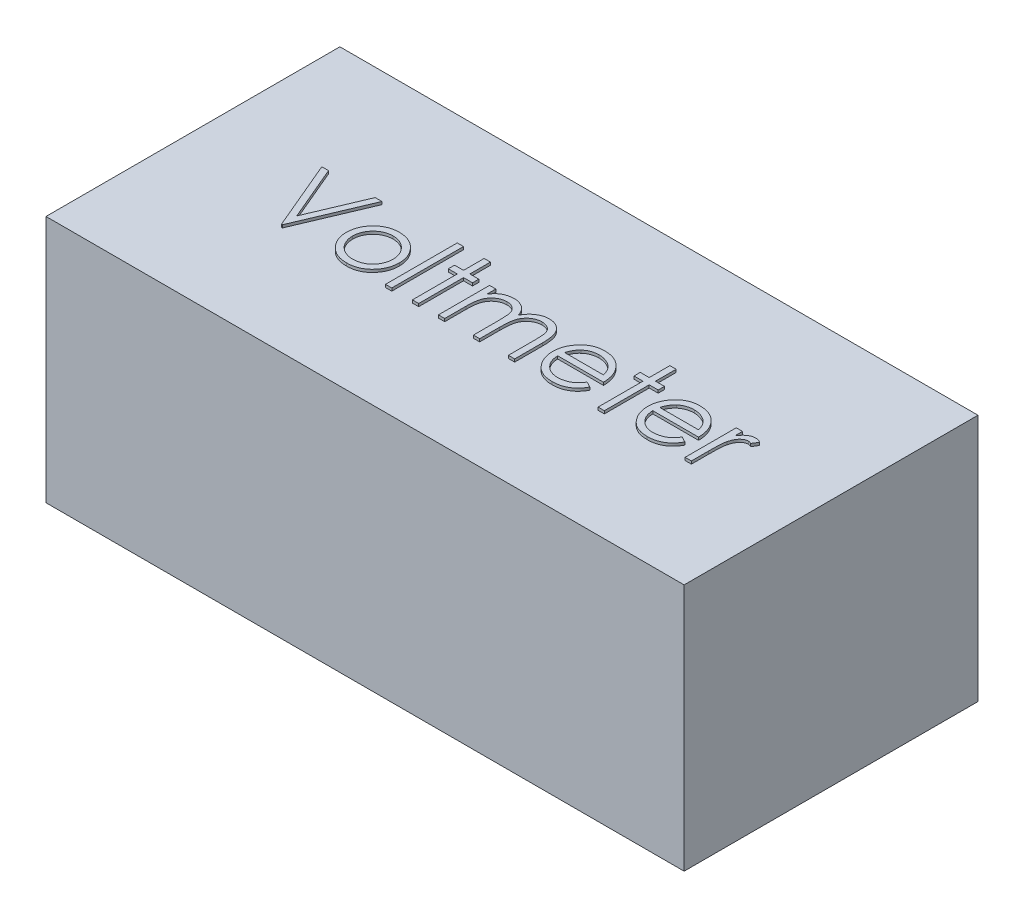
from build123d import *

# Parameters (mm, degrees)
SKETCH1_W           = 22.8
SKETCH1_H           = 10.5
BOSS_EXTRUDE1_DEPTH = 8.86
SKETCH2_W           = 0.224358975
SKETCH2_H           = 2.564102564
BOSS_EXTRUDE2_DEPTH = 0.1


with BuildPart() as part:
    # Sketch1 → Boss-Extrude1 (new body)
    with BuildSketch(Plane(origin=(0, 0, 0), x_dir=(1, 0, 0), z_dir=(0, 1, 0))):
        with Locations((-2.668502582, 3.147934596)):
            Rectangle(SKETCH1_W, SKETCH1_H)
    extrude(amount=BOSS_EXTRUDE1_DEPTH)

    # Sketch2 → Boss-Extrude2 (add)
    with BuildSketch(Plane(origin=(0, 8.86, 0), x_dir=(1, 0, 0), z_dir=(0, 1, 0))):
        Polygon((-10.579076241, 4.262906353), (-10.338691626, 4.262906353), (-9.505358293, 2.292754109), (-8.672024959, 4.262906353), (-8.431640344, 4.262906353), (-9.489332652, 1.762906353), (-9.521383934, 1.762906353), align=None)
        with BuildLine():
            add(Edge.make_bspline(
                [(-7.1646131, 3.621880712), (-7.13033362, 3.621150789), (-7.063119936, 3.61971959), (-6.964685731, 3.604423186), (-6.87072492, 3.581032212), (-6.78087764, 3.548695382), (-6.696294572, 3.505351131), (-6.615743683, 3.453630209), (-6.53944582, 3.392356928), (-6.493715084, 3.344958308), (-6.470502523, 3.320899141)],
                knots=[0, 0, 0, 0, 0.000102763, 0.000201493, 0.000298056, 0.000392956, 0.000487246, 0.000582542, 0.000679761, 0.000779978, 0.000779978, 0.000779978, 0.000779978], degree=3))
            add(Edge.make_bspline(
                [(-6.470502523, 3.320899141), (-6.450515413, 3.297889151), (-6.410927999, 3.252314478), (-6.360166771, 3.178417612), (-6.316437085, 3.101888969), (-6.281392113, 3.021712307), (-6.253759953, 2.938587542), (-6.234141599, 2.852228962), (-6.22247236, 2.762827286), (-6.220898812, 2.702110258), (-6.220101882, 2.671359878)],
                knots=[0, 0, 0, 0, 9.1373e-05, 0.000180977, 0.000268438, 0.000355441, 0.000443018, 0.000530854, 0.000620738, 0.000712972, 0.000712972, 0.000712972, 0.000712972], degree=3))
            add(Edge.make_bspline(
                [(-6.220101882, 2.671359878), (-6.220802838, 2.640431266), (-6.222187958, 2.579314885), (-6.235290541, 2.489301052), (-6.255669888, 2.402019036), (-6.284835487, 2.317834255), (-6.322234136, 2.236489378), (-6.367870341, 2.1583397), (-6.422064354, 2.083231033), (-6.48349578, 2.011801149), (-6.551389977, 1.945968138), (-6.625044369, 1.888590803), (-6.703011536, 1.839432571), (-6.786328217, 1.799835131), (-6.874233565, 1.768613917), (-6.966917185, 1.746685334), (-7.064235092, 1.733426988), (-7.130683107, 1.731724436), (-7.1646131, 1.730855071)],
                knots=[0, 0, 0, 0, 9.2735e-05, 0.000183248, 0.000272287, 0.000361294, 0.000450032, 0.000540478, 0.000632345, 0.000727513, 0.000822787, 0.000915553, 0.001007125, 0.00109874, 0.001191718, 0.001286463, 0.001383991, 0.001485753, 0.001485753, 0.001485753, 0.001485753], degree=3))
            add(Edge.make_bspline(
                [(-7.1646131, 1.730855071), (-7.198709328, 1.731727354), (-7.265488514, 1.733435764), (-7.36314993, 1.746633823), (-7.455999657, 1.768603811), (-7.544020085, 1.799937734), (-7.627694976, 1.839433837), (-7.706113902, 1.888442186), (-7.779828127, 1.945985154), (-7.847736688, 2.011796538), (-7.909164263, 2.083232221), (-7.963359269, 2.158339391), (-8.008995216, 2.236489458), (-8.046393933, 2.317834233), (-8.075559514, 2.402019042), (-8.095938866, 2.489301051), (-8.109041448, 2.579314885), (-8.110426568, 2.640431266), (-8.111127523, 2.671359878)],
                knots=[0, 0, 0, 0, 0.000102263, 0.000200287, 0.000295032, 0.00038801, 0.000480077, 0.000572074, 0.00066484, 0.000760114, 0.000855282, 0.000947149, 0.001037595, 0.001126333, 0.00121534, 0.001304379, 0.001394892, 0.001487627, 0.001487627, 0.001487627, 0.001487627], degree=3))
            add(Edge.make_bspline(
                [(-8.111127523, 2.671359878), (-8.110325159, 2.701943125), (-8.108736615, 2.762492699), (-8.097079108, 2.851726313), (-8.077537282, 2.937938734), (-8.049871999, 3.020742645), (-8.014504006, 3.100567957), (-7.9713888, 3.177285693), (-7.920109777, 3.250848408), (-7.880679811, 3.296364179), (-7.860726882, 3.319396737)],
                knots=[0, 0, 0, 0, 9.1734e-05, 0.000181618, 0.000269454, 0.000356556, 0.0004431, 0.000530998, 0.000620191, 0.000711564, 0.000711564, 0.000711564, 0.000711564], degree=3))
            add(Edge.make_bspline(
                [(-7.860726882, 3.319396737), (-7.837549317, 3.343664551), (-7.791966557, 3.391391477), (-7.715288895, 3.452486137), (-7.634936165, 3.505283333), (-7.549418361, 3.547766344), (-7.459644891, 3.581222428), (-7.365202575, 3.60448351), (-7.26643435, 3.619664478), (-7.198891763, 3.621134605), (-7.1646131, 3.621880712)],
                knots=[0, 0, 0, 0, 0.00010057, 0.000197789, 0.000293357, 0.000388542, 0.000483615, 0.000580177, 0.000679898, 0.000782662, 0.000782662, 0.000782662, 0.000782662], degree=3))
        make_face()
        with BuildLine():
            add(Edge.make_bspline(
                [(-7.165614703, 3.397521737), (-7.189855854, 3.396832743), (-7.237712374, 3.395472541), (-7.308154935, 3.385126895), (-7.37596933, 3.368735821), (-7.441284219, 3.345447209), (-7.503879342, 3.315376567), (-7.56381463, 3.278442024), (-7.621266372, 3.23513277), (-7.675110703, 3.185516576), (-7.724526641, 3.131317294), (-7.767725195, 3.073568466), (-7.804457414, 3.01320679), (-7.835057528, 2.950169496), (-7.857848376, 2.883817772), (-7.874400535, 2.814903036), (-7.884736421, 2.743284881), (-7.886083835, 2.694598439), (-7.886768549, 2.669857475)],
                knots=[0, 0, 0, 0, 7.2701e-05, 0.000143525, 0.000213124, 0.000281711, 0.00035115, 0.000421065, 0.000492579, 0.000566659, 0.000640401, 0.000712316, 0.000782659, 0.000852097, 0.000922102, 0.000992674, 0.00106449, 0.001138691, 0.001138691, 0.001138691, 0.001138691], degree=3))
            add(Edge.make_bspline(
                [(-7.886768549, 2.669857475), (-7.885620818, 2.637891741), (-7.883342786, 2.574445737), (-7.864817617, 2.481009221), (-7.833827417, 2.391307898), (-7.79197936, 2.305867622), (-7.739546347, 2.226815995), (-7.677769871, 2.156336363), (-7.607312942, 2.095489355), (-7.529015442, 2.045003037), (-7.444476643, 2.004888926), (-7.355007842, 1.976461086), (-7.261693061, 1.957981305), (-7.19792111, 1.956144538), (-7.165614703, 1.955214045)],
                knots=[0, 0, 0, 0, 9.5842e-05, 0.000190228, 0.00028446, 0.000379871, 0.000474877, 0.000568205, 0.000660168, 0.000753238, 0.000846877, 0.000940002, 0.001034294, 0.001131105, 0.001131105, 0.001131105, 0.001131105], degree=3))
            add(Edge.make_bspline(
                [(-7.165614703, 1.955214045), (-7.133310154, 1.956149959), (-7.069541871, 1.957997429), (-6.976356744, 1.976368014), (-6.887132479, 2.005013486), (-6.802681488, 2.044957922), (-6.724419628, 2.095681075), (-6.65345597, 2.155992773), (-6.592206962, 2.227002667), (-6.539825816, 2.30597233), (-6.497292428, 2.391175439), (-6.466447284, 2.481025776), (-6.44787758, 2.574441521), (-6.445605559, 2.637890328), (-6.444460857, 2.669857475)],
                knots=[0, 0, 0, 0, 9.6812e-05, 0.000191103, 0.000283751, 0.000377391, 0.00047046, 0.000562803, 0.000655801, 0.000750807, 0.000846441, 0.000940673, 0.001035059, 0.0011309, 0.0011309, 0.0011309, 0.0011309], degree=3))
            add(Edge.make_bspline(
                [(-6.444460857, 2.669857475), (-6.445145335, 2.694598587), (-6.446492285, 2.74328532), (-6.456831545, 2.814901358), (-6.473371216, 2.883823927), (-6.496208086, 2.950146787), (-6.526675238, 3.013370004), (-6.564115805, 3.073391238), (-6.607137966, 3.131517342), (-6.657150195, 3.185341371), (-6.710938322, 3.235152111), (-6.768413349, 3.278458818), (-6.828259763, 3.315214243), (-6.890673036, 3.345704415), (-6.955996299, 3.368523944), (-7.023715677, 3.385221538), (-7.093857684, 3.395428821), (-7.141542714, 3.396819637), (-7.165614703, 3.397521737)],
                knots=[0, 0, 0, 0, 7.4201e-05, 0.000146017, 0.000216589, 0.000286594, 0.000356032, 0.000426636, 0.000498551, 0.000572631, 0.000646711, 0.000718226, 0.000788141, 0.000857128, 0.000926188, 0.0009953, 0.001066124, 0.001138324, 0.001138324, 0.001138324, 0.001138324], degree=3))
        make_face(mode=Mode.SUBTRACT)
        with Locations((-5.691255728, 3.044957635)):
            Rectangle(SKETCH2_W, SKETCH2_H)
        Polygon((-4.841896754, 4.327008917), (-4.61753778, 4.327008917), (-4.61753778, 3.58982943), (-4.297024959, 3.58982943), (-4.297024959, 3.365470455), (-4.61753778, 3.365470455), (-4.61753778, 1.762906353), (-4.841896754, 1.762906353), (-4.841896754, 3.365470455), (-5.162409575, 3.365470455), (-5.162409575, 3.58982943), (-4.841896754, 3.58982943), align=None)
        with BuildLine():
            Line((-3.912409575, 3.58982943), (-3.6880506, 3.58982943))
            Line((-3.6880506, 3.58982943), (-3.6880506, 3.272321417))
            add(Edge.make_bspline(
                [(-3.6880506, 3.272321417), (-3.667847779, 3.300098275), (-3.629137236, 3.353321399), (-3.56566177, 3.423457316), (-3.502250261, 3.482977427), (-3.45658356, 3.514222335), (-3.434645152, 3.529232475)],
                knots=[0, 0, 0, 0, 0.000102966, 0.000197292, 0.000283431, 0.000363073, 0.000363073, 0.000363073, 0.000363073], degree=3))
            add(Edge.make_bspline(
                [(-3.434645152, 3.529232475), (-3.404741821, 3.543522021), (-3.345457607, 3.571851459), (-3.251586732, 3.600589716), (-3.155533397, 3.618250502), (-3.090670387, 3.620665769), (-3.058042587, 3.621880712)],
                knots=[0, 0, 0, 0, 9.9308e-05, 0.000196881, 0.000293544, 0.000391385, 0.000391385, 0.000391385, 0.000391385], degree=3))
            add(Edge.make_bspline(
                [(-3.058042587, 3.621880712), (-3.035976161, 3.621134075), (-2.992307891, 3.619656522), (-2.927604969, 3.610042212), (-2.864848818, 3.593423517), (-2.804410225, 3.570275428), (-2.747466883, 3.54224208), (-2.695260313, 3.509349432), (-2.648385879, 3.472422949), (-2.606867271, 3.42979514), (-2.569532253, 3.380268998), (-2.535190219, 3.32250882), (-2.503457925, 3.255217634), (-2.485871276, 3.20638439), (-2.476612299, 3.180674782)],
                knots=[0, 0, 0, 0, 6.6199e-05, 0.000131004, 0.000195748, 0.000260577, 0.000324855, 0.00038585, 0.00044537, 0.00050345, 0.000563848, 0.000631011, 0.000704712, 0.000786656, 0.000786656, 0.000786656, 0.000786656], degree=3))
            add(Edge.make_bspline(
                [(-2.476612299, 3.180674782), (-2.466818548, 3.198335082), (-2.447545821, 3.233088071), (-2.415184652, 3.282272544), (-2.381279083, 3.328277395), (-2.34554016, 3.371139127), (-2.308094026, 3.410646077), (-2.268764455, 3.446928864), (-2.227775325, 3.480143303), (-2.170780868, 3.518945559), (-2.096629005, 3.560160689), (-2.003137495, 3.595895292), (-1.905887372, 3.617978241), (-1.839874731, 3.620571293), (-1.806540184, 3.621880712)],
                knots=[0, 0, 0, 0, 6.0564e-05, 0.000119181, 0.000176474, 0.000231939, 0.000286492, 0.000339652, 0.000392367, 0.000444597, 0.000546357, 0.000646062, 0.000744001, 0.000843906, 0.000843906, 0.000843906, 0.000843906], degree=3))
            add(Edge.make_bspline(
                [(-1.806540184, 3.621880712), (-1.775910567, 3.620725554), (-1.715965434, 3.618464798), (-1.628695959, 3.600712317), (-1.547308955, 3.570228283), (-1.471968186, 3.528632829), (-1.403996891, 3.476361984), (-1.344913813, 3.414169957), (-1.295077839, 3.342496654), (-1.262521668, 3.275073805), (-1.240439336, 3.215548568), (-1.226824169, 3.164829788), (-1.214795815, 3.10900725), (-1.204809212, 3.048014206), (-1.197510246, 2.981635201), (-1.192102592, 2.909978861), (-1.188442539, 2.832989495), (-1.188183916, 2.779871281), (-1.1880506, 2.752489686)],
                knots=[0, 0, 0, 0, 9.1843e-05, 0.000179747, 0.000265793, 0.000351646, 0.00043699, 0.000522005, 0.000607999, 0.000697811, 0.000745818, 0.000798306, 0.00085518, 0.000917093, 0.000983624, 0.00105545, 0.001132653, 0.001214791, 0.001214791, 0.001214791, 0.001214791], degree=3))
            Line((-1.1880506, 2.752489686), (-1.1880506, 1.762906353))
            Line((-1.1880506, 1.762906353), (-1.412409575, 1.762906353))
            Line((-1.412409575, 1.762906353), (-1.412409575, 2.753491289))
            add(Edge.make_bspline(
                [(-1.412409575, 2.753491289), (-1.412465205, 2.776863127), (-1.412572119, 2.821780246), (-1.414496142, 2.886246283), (-1.418121366, 2.945009395), (-1.422360394, 2.997989458), (-1.428248829, 3.045310021), (-1.435853066, 3.086876035), (-1.443908551, 3.123014471), (-1.457291402, 3.163075934), (-1.478682753, 3.207268941), (-1.511266668, 3.254928638), (-1.552316744, 3.296414924), (-1.599716855, 3.332428008), (-1.65368003, 3.36170918), (-1.713154832, 3.382620615), (-1.777772012, 3.395565529), (-1.822502575, 3.39685554), (-1.845602684, 3.397521737)],
                knots=[0, 0, 0, 0, 7.0114e-05, 0.000134748, 0.000193447, 0.000246723, 0.00029418, 0.00033642, 0.000373469, 0.000405143, 0.000462933, 0.000520167, 0.000577538, 0.000637235, 0.000698186, 0.000760913, 0.000825735, 0.000894962, 0.000894962, 0.000894962, 0.000894962], degree=3))
            add(Edge.make_bspline(
                [(-1.845602684, 3.397521737), (-1.873938365, 3.396510196), (-1.929940445, 3.394511007), (-2.011687221, 3.374101098), (-2.090237947, 3.34332949), (-2.163248756, 3.298734878), (-2.230411464, 3.245300332), (-2.288196876, 3.181764907), (-2.335934152, 3.109886387), (-2.36825842, 3.043353028), (-2.38867935, 2.98358914), (-2.402162861, 2.931376731), (-2.412650998, 2.872032754), (-2.42248709, 2.805955975), (-2.428906896, 2.732691561), (-2.434741447, 2.652578417), (-2.437470635, 2.565375589), (-2.437852391, 2.504927954), (-2.4380506, 2.473543372)],
                knots=[0, 0, 0, 0, 8.4849e-05, 0.000167693, 0.000251297, 0.000337098, 0.000423288, 0.000508012, 0.000593573, 0.000681378, 0.000729048, 0.000782858, 0.000842971, 0.000909758, 0.000983211, 0.001063528, 0.001150719, 0.001244875, 0.001244875, 0.001244875, 0.001244875], degree=3))
            Line((-2.4380506, 2.473543372), (-2.4380506, 1.762906353))
            Line((-2.4380506, 1.762906353), (-2.662409575, 1.762906353))
            Line((-2.662409575, 1.762906353), (-2.662409575, 2.691892731))
            add(Edge.make_bspline(
                [(-2.662409575, 2.691892731), (-2.662466311, 2.718102244), (-2.662575466, 2.768526714), (-2.664487121, 2.840836482), (-2.668120423, 2.906608682), (-2.672320814, 2.96576687), (-2.678363799, 3.018203534), (-2.685227915, 3.064199789), (-2.693334065, 3.103640326), (-2.706755411, 3.146899887), (-2.727265746, 3.194557689), (-2.760257361, 3.245372704), (-2.801405633, 3.289849916), (-2.849670544, 3.327820451), (-2.903960317, 3.359207223), (-2.963948461, 3.381821332), (-3.029094827, 3.394981539), (-3.074007474, 3.396659036), (-3.097105087, 3.397521737)],
                knots=[0, 0, 0, 0, 7.8627e-05, 0.000151271, 0.00021697, 0.000276236, 0.000329162, 0.000375271, 0.00041574, 0.000449799, 0.000511021, 0.000570751, 0.000630649, 0.000691968, 0.000754333, 0.000818047, 0.000883459, 0.000952716, 0.000952716, 0.000952716, 0.000952716], degree=3))
            add(Edge.make_bspline(
                [(-3.097105087, 3.397521737), (-3.124259524, 3.396428552), (-3.178377352, 3.394249871), (-3.257878759, 3.374639676), (-3.334654248, 3.343922479), (-3.407479032, 3.301308323), (-3.474389138, 3.248523267), (-3.532966472, 3.186441198), (-3.582211133, 3.115834746), (-3.614876715, 3.050002948), (-3.635947054, 2.991736323), (-3.649943722, 2.942199932), (-3.661972026, 2.887199755), (-3.670910613, 2.826566104), (-3.679539481, 2.760693894), (-3.683703987, 2.689254973), (-3.687755103, 2.612310624), (-3.687949685, 2.559187378), (-3.6880506, 2.531636321)],
                knots=[0, 0, 0, 0, 8.1352e-05, 0.000162132, 0.000244155, 0.000328761, 0.000414326, 0.000498997, 0.000583882, 0.000671677, 0.000718571, 0.000769613, 0.000825997, 0.000887337, 0.000953429, 0.001025219, 0.001101921, 0.00118456, 0.00118456, 0.00118456, 0.00118456], degree=3))
            Line((-3.6880506, 2.531636321), (-3.6880506, 1.762906353))
            Line((-3.6880506, 1.762906353), (-3.912409575, 1.762906353))
            Line((-3.912409575, 1.762906353), (-3.912409575, 3.58982943))
        make_face()
        with BuildLine():
            Line((0.824168951, 2.33982943), (1.023487861, 2.235161962))
            add(Edge.make_bspline(
                [(1.023487861, 2.235161962), (1.007604579, 2.206988154), (0.976702002, 2.15217308), (0.92355861, 2.076864608), (0.867849987, 2.00911624), (0.807061438, 1.950737915), (0.743011668, 1.899844069), (0.675345486, 1.855317051), (0.603710616, 1.817375251), (0.52810367, 1.78540916), (0.447889704, 1.76083095), (0.362874336, 1.743470792), (0.272894696, 1.732739886), (0.211218853, 1.731493357), (0.179637701, 1.730855071)],
                knots=[0, 0, 0, 0, 9.6971e-05, 0.000188667, 0.000276128, 0.000359712, 0.000440975, 0.000521259, 0.00060236, 0.000683837, 0.000767159, 0.000853591, 0.000943849, 0.001038565, 0.001038565, 0.001038565, 0.001038565], degree=3))
            add(Edge.make_bspline(
                [(0.179637701, 1.730855071), (0.144536289, 1.731674482), (0.076063602, 1.733272915), (-0.023607646, 1.747053247), (-0.117450088, 1.769533503), (-0.205458448, 1.800937461), (-0.287417199, 1.841956978), (-0.363489239, 1.891928037), (-0.434074614, 1.950593933), (-0.496949049, 2.018462821), (-0.553551823, 2.091092791), (-0.603498837, 2.166775565), (-0.645254145, 2.245320726), (-0.679220295, 2.326228243), (-0.706652341, 2.408988167), (-0.725771416, 2.494353501), (-0.736792664, 2.582093204), (-0.738481554, 2.641448444), (-0.739332652, 2.671359878)],
                knots=[0, 0, 0, 0, 0.000105265, 0.000205341, 0.000301178, 0.000394324, 0.00048503, 0.000575455, 0.000666827, 0.00075965, 0.000852416, 0.000942841, 0.001031335, 0.001118861, 0.001205806, 0.001292554, 0.001380884, 0.001470617, 0.001470617, 0.001470617, 0.001470617], degree=3))
            add(Edge.make_bspline(
                [(-0.739332652, 2.671359878), (-0.738576122, 2.699427614), (-0.73707678, 2.755054161), (-0.727626218, 2.837386692), (-0.710877437, 2.917407016), (-0.687894349, 2.995181621), (-0.658214887, 3.070580288), (-0.621906159, 3.143648905), (-0.578911604, 3.214309719), (-0.545716837, 3.258883386), (-0.528996113, 3.28133584)],
                knots=[0, 0, 0, 0, 8.4208e-05, 0.000166888, 0.000248213, 0.000329183, 0.000409905, 0.000490981, 0.000573692, 0.000657642, 0.000657642, 0.000657642, 0.000657642], degree=3))
            add(Edge.make_bspline(
                [(-0.528996113, 3.28133584), (-0.506347768, 3.308385033), (-0.461768521, 3.361626569), (-0.386371124, 3.431582516), (-0.304728127, 3.490185212), (-0.217862679, 3.538761738), (-0.124765198, 3.575671486), (-0.026687133, 3.603176902), (0.077488286, 3.618589767), (0.148706301, 3.620766791), (0.185146515, 3.621880712)],
                knots=[0, 0, 0, 0, 0.000105765, 0.00020818, 0.000307557, 0.000406641, 0.000505962, 0.000607293, 0.00071162, 0.000820933, 0.000820933, 0.000820933, 0.000820933], degree=3))
            add(Edge.make_bspline(
                [(0.185146515, 3.621880712), (0.22260909, 3.620913534), (0.296102123, 3.619016152), (0.403267924, 3.601425913), (0.504668436, 3.573531232), (0.600263082, 3.534135667), (0.690061554, 3.483307416), (0.77348016, 3.420348957), (0.851945527, 3.347193181), (0.897594511, 3.290933746), (0.920823598, 3.262305391)],
                knots=[0, 0, 0, 0, 0.000112315, 0.000220336, 0.000324831, 0.000427226, 0.000529719, 0.000633485, 0.000740123, 0.000850609, 0.000850609, 0.000850609, 0.000850609], degree=3))
            add(Edge.make_bspline(
                [(0.920823598, 3.262305391), (0.936628554, 3.240731404), (0.968133264, 3.197727034), (1.007595478, 3.127604779), (1.04185076, 3.054240069), (1.069231447, 2.976446999), (1.091402519, 2.895147299), (1.107443104, 2.809759767), (1.116849974, 2.720309831), (1.118699044, 2.659362291), (1.119641707, 2.628290968)],
                knots=[0, 0, 0, 0, 8.0167e-05, 0.000159801, 0.000240914, 0.000322808, 0.000406877, 0.000493509, 0.000583158, 0.000676393, 0.000676393, 0.000676393, 0.000676393], degree=3))
            Line((1.119641707, 2.628290968), (-0.514973677, 2.628290968))
            add(Edge.make_bspline(
                [(-0.514973677, 2.628290968), (-0.513873958, 2.604219208), (-0.511711405, 2.556883062), (-0.50162916, 2.487618217), (-0.485737179, 2.421637259), (-0.463402134, 2.359435086), (-0.436354388, 2.30019928), (-0.403221733, 2.244369254), (-0.36369348, 2.192199304), (-0.319603695, 2.143222777), (-0.270527198, 2.099607948), (-0.218896664, 2.060570965), (-0.163972689, 2.027852681), (-0.106188344, 2.001295617), (-0.045637069, 1.980505391), (0.017700213, 1.966314091), (0.083698868, 1.956809015), (0.128688678, 1.955752111), (0.151592829, 1.955214045)],
                knots=[0, 0, 0, 0, 7.2256e-05, 0.000142089, 0.000209623, 0.000275516, 0.000340049, 0.000404722, 0.000469826, 0.000536124, 0.000602085, 0.000666488, 0.000730044, 0.000793459, 0.000856966, 0.000921716, 0.000987938, 0.001056613, 0.001056613, 0.001056613, 0.001056613], degree=3))
            add(Edge.make_bspline(
                [(0.151592829, 1.955214045), (0.173986506, 1.955648371), (0.218419857, 1.956510158), (0.284591898, 1.964890094), (0.34969156, 1.978440291), (0.413449405, 1.996933141), (0.474571438, 2.019488035), (0.531175402, 2.046704362), (0.583232699, 2.076811324), (0.631887675, 2.111246806), (0.679081242, 2.153395511), (0.725897304, 2.205992455), (0.776094913, 2.268197832), (0.807516051, 2.315016165), (0.824168951, 2.33982943)],
                knots=[0, 0, 0, 0, 6.7154e-05, 0.000133247, 0.00019974, 0.000266467, 0.000332232, 0.000394953, 0.000454649, 0.000512458, 0.00057347, 0.000644012, 0.000723475, 0.000813079, 0.000813079, 0.000813079, 0.000813079], degree=3))
        make_face()
        with BuildLine():
            add(Edge.make_bspline(
                [(0.895282733, 2.852649942), (0.887070858, 2.882409138), (0.871265643, 2.93968601), (0.838239668, 3.019000932), (0.801045711, 3.089492289), (0.757030188, 3.150620599), (0.70715967, 3.204908822), (0.649555968, 3.252350669), (0.584958901, 3.294791705), (0.513702372, 3.330614919), (0.438243954, 3.361107675), (0.359239532, 3.381554187), (0.278626826, 3.395561003), (0.224102336, 3.396865366), (0.196664945, 3.397521737)],
                knots=[0, 0, 0, 0, 9.253e-05, 0.000178091, 0.000257189, 0.000331125, 0.000403421, 0.000477737, 0.000554411, 0.000634817, 0.000716655, 0.000798045, 0.000879224, 0.000961454, 0.000961454, 0.000961454, 0.000961454], degree=3))
            add(Edge.make_bspline(
                [(0.196664945, 3.397521737), (0.174272489, 3.397084829), (0.130007311, 3.396221153), (0.064792262, 3.388028204), (0.002163906, 3.374485457), (-0.058339871, 3.35593906), (-0.115926206, 3.33121863), (-0.171779612, 3.302230611), (-0.224479895, 3.266843765), (-0.257437963, 3.239873154), (-0.27408826, 3.226247699)],
                knots=[0, 0, 0, 0, 6.7154e-05, 0.000132749, 0.000196793, 0.000259203, 0.000322266, 0.000384543, 0.000447741, 0.000512267, 0.000512267, 0.000512267, 0.000512267], degree=3))
            add(Edge.make_bspline(
                [(-0.27408826, 3.226247699), (-0.286012033, 3.215466045), (-0.310142843, 3.193646605), (-0.342386073, 3.156054314), (-0.373257839, 3.115517484), (-0.401353306, 3.070485252), (-0.42712301, 3.02147041), (-0.45123728, 2.968886385), (-0.47294186, 2.912334149), (-0.485153367, 2.872925264), (-0.491436017, 2.852649942)],
                knots=[0, 0, 0, 0, 4.8181e-05, 9.7507e-05, 0.000148288, 0.000200949, 0.000256508, 0.000314326, 0.000374408, 0.000438075, 0.000438075, 0.000438075, 0.000438075], degree=3))
            Line((-0.491436017, 2.852649942), (0.895282733, 2.852649942))
        make_face(mode=Mode.SUBTRACT)
        Polygon((1.792718631, 4.327008917), (2.017077605, 4.327008917), (2.017077605, 3.58982943), (2.337590425, 3.58982943), (2.337590425, 3.365470455), (2.017077605, 3.365470455), (2.017077605, 1.762906353), (1.792718631, 1.762906353), (1.792718631, 3.365470455), (1.47220581, 3.365470455), (1.47220581, 3.58982943), (1.792718631, 3.58982943), align=None)
        with BuildLine():
            Line((4.221604848, 2.33982943), (4.420923759, 2.235161962))
            add(Edge.make_bspline(
                [(4.420923759, 2.235161962), (4.405040476, 2.206988154), (4.374137899, 2.15217308), (4.320994508, 2.076864608), (4.265285884, 2.00911624), (4.204497336, 1.950737915), (4.140447565, 1.899844069), (4.072781383, 1.855317051), (4.001146513, 1.817375251), (3.925539567, 1.78540916), (3.845325602, 1.76083095), (3.760310233, 1.743470792), (3.670330593, 1.732739886), (3.608654751, 1.731493357), (3.577073598, 1.730855071)],
                knots=[0, 0, 0, 0, 9.6971e-05, 0.000188667, 0.000276128, 0.000359712, 0.000440975, 0.000521259, 0.00060236, 0.000683837, 0.000767159, 0.000853591, 0.000943849, 0.001038565, 0.001038565, 0.001038565, 0.001038565], degree=3))
            add(Edge.make_bspline(
                [(3.577073598, 1.730855071), (3.541972186, 1.731674482), (3.473499499, 1.733272915), (3.373828251, 1.747053247), (3.279985809, 1.769533503), (3.19197745, 1.800937461), (3.110018698, 1.841956978), (3.033946659, 1.891928037), (2.963361283, 1.950593933), (2.900486848, 2.018462821), (2.843884075, 2.091092791), (2.79393706, 2.166775565), (2.752181753, 2.245320726), (2.718215602, 2.326228243), (2.690783556, 2.408988167), (2.671664482, 2.494353501), (2.660643233, 2.582093204), (2.658954344, 2.641448444), (2.658103246, 2.671359878)],
                knots=[0, 0, 0, 0, 0.000105265, 0.000205341, 0.000301178, 0.000394324, 0.00048503, 0.000575455, 0.000666827, 0.00075965, 0.000852416, 0.000942841, 0.001031335, 0.001118861, 0.001205806, 0.001292554, 0.001380884, 0.001470617, 0.001470617, 0.001470617, 0.001470617], degree=3))
            add(Edge.make_bspline(
                [(2.658103246, 2.671359878), (2.658859775, 2.699427614), (2.660359117, 2.755054161), (2.669809679, 2.837386692), (2.68655846, 2.917407016), (2.709541549, 2.995181621), (2.73922101, 3.070580288), (2.775529738, 3.143648905), (2.818524294, 3.214309719), (2.851719061, 3.258883386), (2.868439784, 3.28133584)],
                knots=[0, 0, 0, 0, 8.4208e-05, 0.000166888, 0.000248213, 0.000329183, 0.000409905, 0.000490981, 0.000573692, 0.000657642, 0.000657642, 0.000657642, 0.000657642], degree=3))
            add(Edge.make_bspline(
                [(2.868439784, 3.28133584), (2.891088129, 3.308385033), (2.935667377, 3.361626569), (3.011064773, 3.431582516), (3.092707771, 3.490185212), (3.179573218, 3.538761738), (3.2726707, 3.575671486), (3.370748765, 3.603176902), (3.474924183, 3.618589767), (3.546142198, 3.620766791), (3.582582413, 3.621880712)],
                knots=[0, 0, 0, 0, 0.000105765, 0.00020818, 0.000307557, 0.000406641, 0.000505962, 0.000607293, 0.00071162, 0.000820933, 0.000820933, 0.000820933, 0.000820933], degree=3))
            add(Edge.make_bspline(
                [(3.582582413, 3.621880712), (3.620044988, 3.620913534), (3.693538021, 3.619016152), (3.800703821, 3.601425913), (3.902104333, 3.573531232), (3.997698979, 3.534135667), (4.087497451, 3.483307416), (4.170916058, 3.420348957), (4.249381424, 3.347193181), (4.295030409, 3.290933746), (4.318259496, 3.262305391)],
                knots=[0, 0, 0, 0, 0.000112315, 0.000220336, 0.000324831, 0.000427226, 0.000529719, 0.000633485, 0.000740123, 0.000850609, 0.000850609, 0.000850609, 0.000850609], degree=3))
            add(Edge.make_bspline(
                [(4.318259496, 3.262305391), (4.334064452, 3.240731404), (4.365569161, 3.197727034), (4.405031376, 3.127604779), (4.439286658, 3.054240069), (4.466667344, 2.976446999), (4.488838416, 2.895147299), (4.504879001, 2.809759767), (4.514285872, 2.720309831), (4.516134941, 2.659362291), (4.517077605, 2.628290968)],
                knots=[0, 0, 0, 0, 8.0167e-05, 0.000159801, 0.000240914, 0.000322808, 0.000406877, 0.000493509, 0.000583158, 0.000676393, 0.000676393, 0.000676393, 0.000676393], degree=3))
            Line((4.517077605, 2.628290968), (2.88246222, 2.628290968))
            add(Edge.make_bspline(
                [(2.88246222, 2.628290968), (2.883561939, 2.604219208), (2.885724492, 2.556883062), (2.895806737, 2.487618217), (2.911698718, 2.421637259), (2.934033763, 2.359435086), (2.96108151, 2.30019928), (2.994214165, 2.244369254), (3.033742417, 2.192199304), (3.077832203, 2.143222777), (3.126908699, 2.099607948), (3.178539233, 2.060570965), (3.233463208, 2.027852681), (3.291247553, 2.001295617), (3.351798829, 1.980505391), (3.415136111, 1.966314091), (3.481134765, 1.956809015), (3.526124575, 1.955752111), (3.549028727, 1.955214045)],
                knots=[0, 0, 0, 0, 7.2256e-05, 0.000142089, 0.000209623, 0.000275516, 0.000340049, 0.000404722, 0.000469826, 0.000536124, 0.000602085, 0.000666488, 0.000730044, 0.000793459, 0.000856966, 0.000921716, 0.000987938, 0.001056613, 0.001056613, 0.001056613, 0.001056613], degree=3))
            add(Edge.make_bspline(
                [(3.549028727, 1.955214045), (3.571422404, 1.955648371), (3.615855754, 1.956510158), (3.682027795, 1.964890094), (3.747127458, 1.978440291), (3.810885303, 1.996933141), (3.872007336, 2.019488035), (3.9286113, 2.046704362), (3.980668597, 2.076811324), (4.029323573, 2.111246806), (4.07651714, 2.153395511), (4.123333201, 2.205992455), (4.173530811, 2.268197832), (4.204951949, 2.315016165), (4.221604848, 2.33982943)],
                knots=[0, 0, 0, 0, 6.7154e-05, 0.000133247, 0.00019974, 0.000266467, 0.000332232, 0.000394953, 0.000454649, 0.000512458, 0.00057347, 0.000644012, 0.000723475, 0.000813079, 0.000813079, 0.000813079, 0.000813079], degree=3))
        make_face()
        with BuildLine():
            add(Edge.make_bspline(
                [(4.292718631, 2.852649942), (4.284506756, 2.882409138), (4.268701541, 2.93968601), (4.235675566, 3.019000932), (4.198481608, 3.089492289), (4.154466086, 3.150620599), (4.104595568, 3.204908822), (4.046991866, 3.252350669), (3.982394799, 3.294791705), (3.91113827, 3.330614919), (3.835679852, 3.361107675), (3.756675429, 3.381554187), (3.676062723, 3.395561003), (3.621538233, 3.396865366), (3.594100842, 3.397521737)],
                knots=[0, 0, 0, 0, 9.253e-05, 0.000178091, 0.000257189, 0.000331125, 0.000403421, 0.000477737, 0.000554411, 0.000634817, 0.000716655, 0.000798045, 0.000879224, 0.000961454, 0.000961454, 0.000961454, 0.000961454], degree=3))
            add(Edge.make_bspline(
                [(3.594100842, 3.397521737), (3.571708386, 3.397084829), (3.527443208, 3.396221153), (3.462228159, 3.388028204), (3.399599803, 3.374485457), (3.339096026, 3.35593906), (3.281509692, 3.33121863), (3.225656286, 3.302230611), (3.172956003, 3.266843765), (3.139997934, 3.239873154), (3.123347637, 3.226247699)],
                knots=[0, 0, 0, 0, 6.7154e-05, 0.000132749, 0.000196793, 0.000259203, 0.000322266, 0.000384543, 0.000447741, 0.000512267, 0.000512267, 0.000512267, 0.000512267], degree=3))
            add(Edge.make_bspline(
                [(3.123347637, 3.226247699), (3.111423864, 3.215466045), (3.087293054, 3.193646605), (3.055049824, 3.156054314), (3.024178058, 3.115517484), (2.996082592, 3.070485252), (2.970312887, 3.02147041), (2.946198618, 2.968886385), (2.924494038, 2.912334149), (2.912282531, 2.872925264), (2.905999881, 2.852649942)],
                knots=[0, 0, 0, 0, 4.8181e-05, 9.7507e-05, 0.000148288, 0.000200949, 0.000256508, 0.000314326, 0.000374408, 0.000438075, 0.000438075, 0.000438075, 0.000438075], degree=3))
            Line((2.905999881, 2.852649942), (4.292718631, 2.852649942))
        make_face(mode=Mode.SUBTRACT)
        with BuildLine():
            Line((4.90169299, 3.58982943), (5.126051964, 3.58982943))
            Line((5.126051964, 3.58982943), (5.126051964, 3.320899141))
            add(Edge.make_bspline(
                [(5.126051964, 3.320899141), (5.142615363, 3.345939019), (5.174292735, 3.393827589), (5.226944827, 3.457162804), (5.280875778, 3.509602123), (5.336343769, 3.551390351), (5.393756698, 3.582685436), (5.45185452, 3.605609032), (5.511551285, 3.619164258), (5.551666945, 3.620974014), (5.571765105, 3.621880712)],
                knots=[0, 0, 0, 0, 9.0016e-05, 0.000172155, 0.000246534, 0.000315244, 0.000379793, 0.000442104, 0.000502127, 0.000562392, 0.000562392, 0.000562392, 0.000562392], degree=3))
            add(Edge.make_bspline(
                [(5.571765105, 3.621880712), (5.587355338, 3.621030336), (5.619433256, 3.619280631), (5.667992249, 3.606987185), (5.718023286, 3.587360026), (5.750267848, 3.568902724), (5.767077605, 3.559280551)],
                knots=[0, 0, 0, 0, 4.6747e-05, 9.6184e-05, 0.000149472, 0.000207506, 0.000207506, 0.000207506, 0.000207506], degree=3))
            Line((5.767077605, 3.559280551), (5.64388049, 3.364969654))
            add(Edge.make_bspline(
                [(5.64388049, 3.364969654), (5.633088332, 3.36978413), (5.61260275, 3.378922927), (5.582635202, 3.389738648), (5.555005676, 3.396107159), (5.537403134, 3.397071958), (5.529196996, 3.397521737)],
                knots=[0, 0, 0, 0, 3.5444e-05, 6.7279e-05, 9.5471e-05, 0.000120092, 0.000120092, 0.000120092, 0.000120092], degree=3))
            add(Edge.make_bspline(
                [(5.529196996, 3.397521737), (5.511192901, 3.396321711), (5.474469765, 3.393874004), (5.420552265, 3.374631998), (5.368232833, 3.343542541), (5.326681645, 3.309063176), (5.294508608, 3.275814749), (5.271551304, 3.246780176), (5.250492199, 3.21422401), (5.230370613, 3.178702808), (5.212037545, 3.13961006), (5.194927067, 3.097336336), (5.179456451, 3.051832673), (5.170634848, 3.020130873), (5.166116066, 3.00389193)],
                knots=[0, 0, 0, 0, 5.3922e-05, 0.000109985, 0.000169681, 0.000235855, 0.000271274, 0.000308347, 0.000346683, 0.000387495, 0.000430729, 0.000476112, 0.000524257, 0.000574818, 0.000574818, 0.000574818, 0.000574818], degree=3))
            add(Edge.make_bspline(
                [(5.166116066, 3.00389193), (5.162735785, 2.989408234), (5.15524872, 2.957327949), (5.14796905, 2.903507575), (5.140776537, 2.839919247), (5.135707524, 2.766385966), (5.131008923, 2.683091364), (5.128358864, 2.589908545), (5.126142335, 2.486741866), (5.126083001, 2.414617328), (5.126051964, 2.376888725)],
                knots=[0, 0, 0, 0, 4.4597e-05, 9.8778e-05, 0.000162765, 0.000236589, 0.000319844, 0.000413041, 0.000516226, 0.000629408, 0.000629408, 0.000629408, 0.000629408], degree=3))
            Line((5.126051964, 2.376888725), (5.126051964, 1.762906353))
            Line((5.126051964, 1.762906353), (4.90169299, 1.762906353))
            Line((4.90169299, 1.762906353), (4.90169299, 3.58982943))
        make_face()
    extrude(amount=BOSS_EXTRUDE2_DEPTH)


solid = part.part
